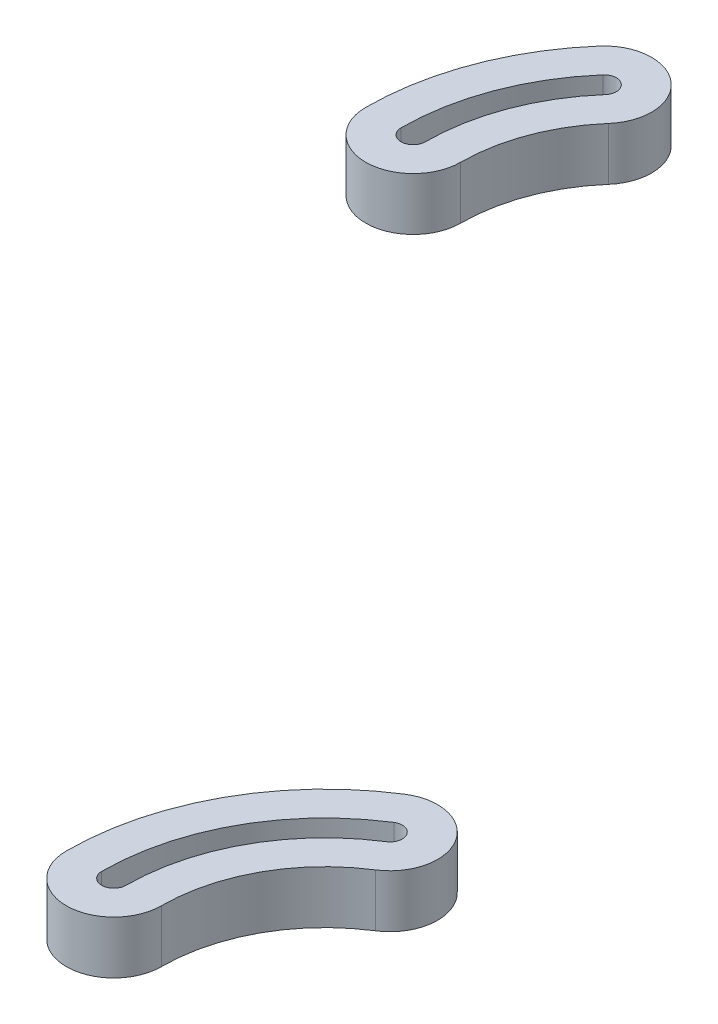
from build123d import *

# Parameters (mm, degrees)
DODANIE_WYCI_GNI_CIE1_DEPTH   = 10
DODANIE_WYCI_GNI_CIE1_2_DEPTH = 10


with BuildPart() as part:
    # Szkic1 → Dodanie-wyciągnięcie1 (new body)
    with BuildSketch(Plane(origin=(0, 455.3, 0), x_dir=(1, 0, 0), z_dir=(0, 1, 0))):
        with BuildLine():
            ThreePointArc((-111.762653418, -370.544409902), (-128.45073709, -388.311287346), (-134.513533731, -411.920534849))
            ThreePointArc((-134.513533731, -411.920534849), (-125.513533731, -420.920534849), (-116.513533731, -411.920534849))
            ThreePointArc((-116.513533731, -411.920534849), (-112.677886877, -396.984072143), (-102.120119655, -385.743802739))
            ThreePointArc((-102.120119655, -385.743802739), (-99.341690118, -373.322839439), (-111.762653418, -370.544409902))
        make_face()
        with BuildLine():
            ThreePointArc((-105.709285, -380.086250961), (-104.999241896, -376.912004784), (-108.173488073, -376.20196168))
            ThreePointArc((-108.173488073, -376.20196168), (-122.579731733, -391.539490576), (-127.813533731, -411.920534849))
            ThreePointArc((-127.813533731, -411.920534849), (-125.513533731, -414.220534849), (-123.213533731, -411.920534849))
            ThreePointArc((-123.213533731, -411.920534849), (-118.548892234, -393.755868913), (-105.709285, -380.086250961))
        make_face(mode=Mode.SUBTRACT)
    extrude(amount=-DODANIE_WYCI_GNI_CIE1_DEPTH)


with BuildPart() as body_2:
    # Szkic1 → Dodanie-wyci_gni_cie1 2 (new body)
    with BuildSketch(Plane(origin=(0, 455.3, 0), x_dir=(1, 0, 0), z_dir=(0, 1, 0))):
        with BuildLine():
            ThreePointArc((-228.166238959, -261.544556892), (-219.166238959, -270.544556892), (-210.166238959, -261.544556892))
            ThreePointArc((-210.166238959, -261.544556892), (-208.190571246, -250.654738927), (-202.51539152, -241.152963656))
            ThreePointArc((-202.51539152, -241.152963656), (-203.374037775, -228.454037457), (-216.072963974, -229.312683713))
            ThreePointArc((-216.072963974, -229.312683713), (-225.043409348, -244.331618818), (-228.166238959, -261.544556892))
        make_face()
        with BuildLine():
            ThreePointArc((-207.561821267, -236.745748344), (-207.781253087, -233.500467204), (-211.026534227, -233.719899025))
            ThreePointArc((-211.026534227, -233.719899025), (-218.770408499, -246.685224637), (-221.466238959, -261.544556892))
            ThreePointArc((-221.466238959, -261.544556892), (-219.166238959, -263.844556892), (-216.866238959, -261.544556892))
            ThreePointArc((-216.866238959, -261.544556892), (-214.463572095, -248.301133109), (-207.561821267, -236.745748344))
        make_face(mode=Mode.SUBTRACT)
    extrude(amount=-DODANIE_WYCI_GNI_CIE1_2_DEPTH)


solid = Compound([part.part, body_2.part])
